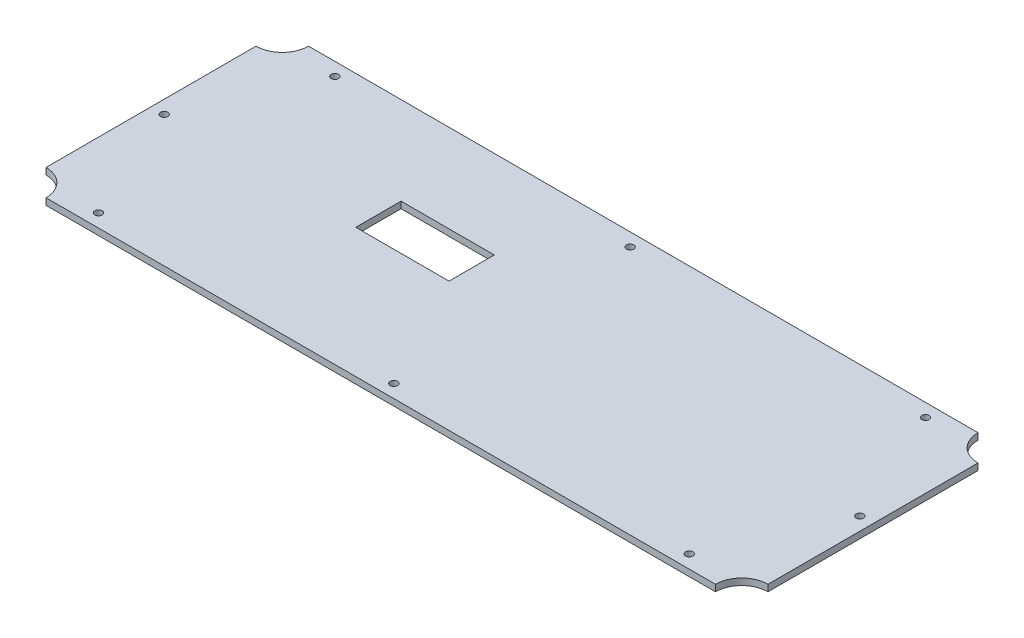
from build123d import *

# Parameters (mm, degrees)
SKETCH3_W                                  = 279.4
SKETCH3_H                                  = 101.6
RECTANGLE_CUT_DEPTH                        = 5.08
SKETCH4_R                                  = 10.16
CUT_EXTRUDE2_DEPTH                         = 7.62
MIRROR3_COPY_1_SKETCH_R                    = 10.16
MIRROR3_COPY_1_DEPTH                       = 7.62
SKETCH6_W                                  = 36.068
SKETCH6_H                                  = 17.526
CUT_EXTRUDE3_DEPTH                         = 7.62
SKETCH9_W                                  = 329.627948334
SKETCH9_H                                  = 121.564544856
CUT_EXTRUDE5_DEPTH                         = 2.54
SKETCH11_R                                 = 1.4224
CUT_EXTRUDE6_DEPTH                         = 2.54
MIRROR4_AT_THE_SECOND_PLANE_COPY_1_SKETC_R = 1.4224
MIRROR4_AT_THE_SECOND_PLANE_COPY_1_DEPTH   = 2.54
SKETCH12_R                                 = 1.4224
CUT_EXTRUDE7_DEPTH                         = 2.54
SKETCH13_R                                 = 1.4224
CUT_EXTRUDE8_DEPTH                         = 2.54


with BuildPart() as part:
    # Sketch3 → Rectangle cut (new body)
    with BuildSketch(Plane(origin=(0, 0, 0), x_dir=(1, 0, 0), z_dir=(0, 1, 0))):
        Rectangle(SKETCH3_W, SKETCH3_H)
    extrude(amount=-RECTANGLE_CUT_DEPTH)

    # Sketch4 → Cut-Extrude2 (cut)
    with BuildSketch(Plane(origin=(0, 0, 0), x_dir=(1, 0, 0), z_dir=(0, 1, 0))):
        with Locations((-139.7, -50.8)):
            Circle(SKETCH4_R)
    cut_extrude2 = extrude(amount=-CUT_EXTRUDE2_DEPTH, mode=Mode.SUBTRACT)

    # mountingCorners: Cut-Extrude2 across plane
    add(cut_extrude2.mirror(Plane(origin=(0, 0, 0), x_dir=(0, 0, 1), z_dir=(1, 0, 0))), mode=Mode.SUBTRACT)

    # Mirror3: Cut-Extrude2 across plane
    add(cut_extrude2.mirror(Plane.XY), mode=Mode.SUBTRACT)

    # Mirror3 copy 1 sketch → Mirror3 copy 1 (cut)
    with BuildSketch(Plane(origin=(0, 0, 0), x_dir=(-1, 0, 0), z_dir=(0, 1, 0))):
        with Locations((-139.7, -50.8)):
            Circle(MIRROR3_COPY_1_SKETCH_R)
    extrude(amount=-MIRROR3_COPY_1_DEPTH, mode=Mode.SUBTRACT)

    # Sketch6 → Cut-Extrude3 (cut)
    with BuildSketch(Plane(origin=(0, 0, 0), x_dir=(1, 0, 0), z_dir=(0, 1, 0))):
        with Locations((-41.656, 8.001)):
            Rectangle(SKETCH6_W, SKETCH6_H)
    extrude(amount=-CUT_EXTRUDE3_DEPTH, mode=Mode.SUBTRACT)

    # Sketch9 → Cut-Extrude5 (cut)
    with BuildSketch(Plane.XZ.offset(5.08)):
        Rectangle(SKETCH9_W, SKETCH9_H)
    extrude(amount=-CUT_EXTRUDE5_DEPTH, mode=Mode.SUBTRACT)

    # Sketch11 → Cut-Extrude6 (cut)
    with BuildSketch(Plane.XZ.offset(2.54)):
        with Locations((-114.3, -45.72)):
            Circle(SKETCH11_R)
    cut_extrude6 = extrude(amount=-CUT_EXTRUDE6_DEPTH, mode=Mode.SUBTRACT)

    # Mirror4: Cut-Extrude6 across plane
    add(cut_extrude6.mirror(Plane.XY), mode=Mode.SUBTRACT)

    # Mirror4 at the second plane: Cut-Extrude6 across plane
    add(cut_extrude6.mirror(Plane(origin=(0, 0, 0), x_dir=(0, 0, 1), z_dir=(1, 0, 0))), mode=Mode.SUBTRACT)

    # Mirror4 at the second plane copy 1 sketc → Mirror4 at the second plane copy 1 (cut)
    with BuildSketch(Plane(origin=(0, -2.54, 0), x_dir=(-1, 0, 0), z_dir=(0, -1, 0))):
        with Locations((-114.3, -45.72)):
            Circle(MIRROR4_AT_THE_SECOND_PLANE_COPY_1_SKETC_R)
    extrude(amount=-MIRROR4_AT_THE_SECOND_PLANE_COPY_1_DEPTH, mode=Mode.SUBTRACT)

    # Sketch12 → Cut-Extrude7 (cut)
    with BuildSketch(Plane.XZ.offset(2.54)):
        with Locations((-134.62, 0)):
            Circle(SKETCH12_R)
    cut_extrude7 = extrude(amount=-CUT_EXTRUDE7_DEPTH, mode=Mode.SUBTRACT)

    # Mirror5: Cut-Extrude7 across plane
    add(cut_extrude7.mirror(Plane(origin=(0, 0, 0), x_dir=(0, 0, 1), z_dir=(1, 0, 0))), mode=Mode.SUBTRACT)

    # Sketch13 → Cut-Extrude8 (cut)
    with BuildSketch(Plane.XZ.offset(2.54)):
        with Locations((0, -45.72)):
            Circle(SKETCH13_R)
    cut_extrude8 = extrude(amount=-CUT_EXTRUDE8_DEPTH, mode=Mode.SUBTRACT)

    # Mirror6: Cut-Extrude8 across plane
    add(cut_extrude8.mirror(Plane.XY), mode=Mode.SUBTRACT)


solid = part.part
